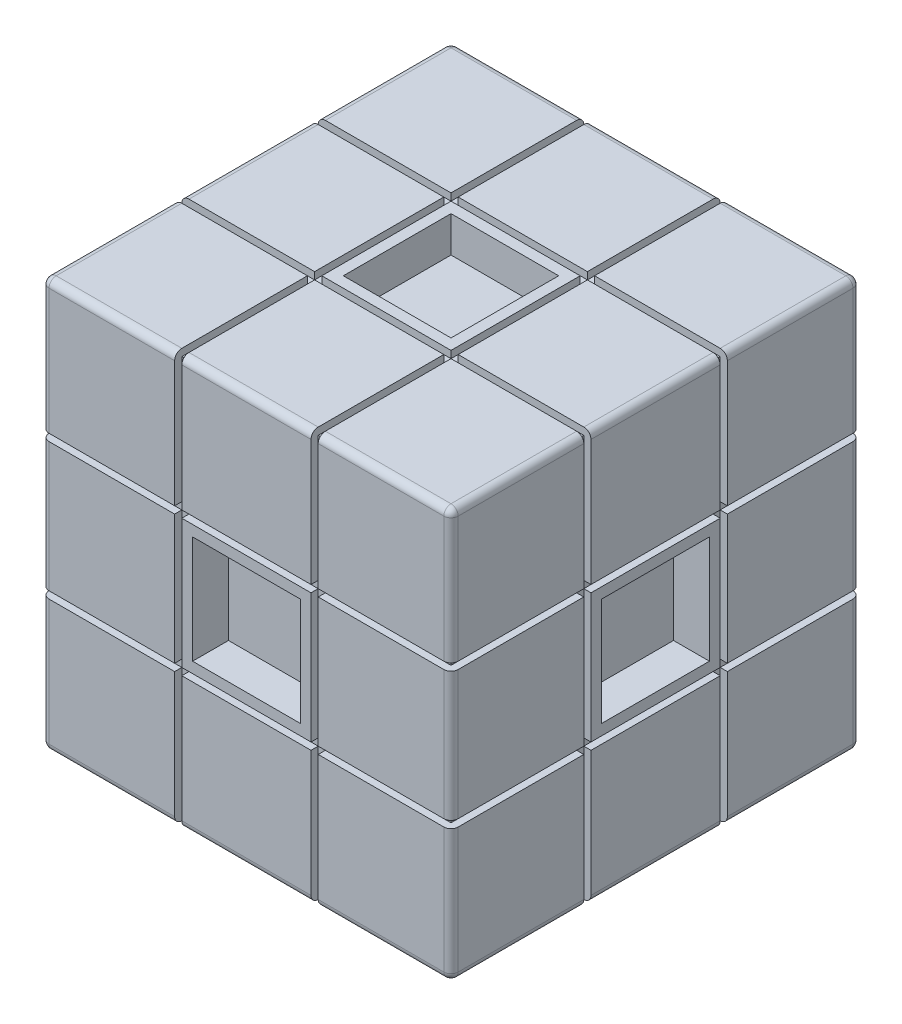
from build123d import *

# Parameters (mm, degrees)
SKETCH_1_W           = 57
SKETCH_1_H           = 57
EXTRUDE_1_DEPTH      = 57
SKETCH_2_W           = 15
SKETCH_2_H           = 15
CUT_EXTRUDE_3_DEPTH  = 5
SKETCH_5_W           = 15
SKETCH_5_H           = 15
CUT_EXTRUDE_4_DEPTH  = 5
SKETCH_6_W           = 15
SKETCH_6_H           = 15
CUT_EXTRUDE_5_DEPTH  = 5
SKETCH_8_W           = 15
SKETCH_8_H           = 15
CUT_EXTRUDE_6_DEPTH  = 5
SKETCH_9_W           = 15
SKETCH_9_H           = 15
CUT_EXTRUDE_7_DEPTH  = 5
SKETCH_10_W          = 15
SKETCH_10_H          = 15
CUT_EXTRUDE_8_DEPTH  = 5
SKETCH_12_W          = 18
SKETCH_12_H          = 18
CUT_EXTRUDE_9_DEPTH  = 1
SKETCH_13_W          = 1
SKETCH_13_H          = 1
CUT_EXTRUDE_10_DEPTH = 58
SKETCH_14_W          = 1
SKETCH_14_H          = 1
CUT_EXTRUDE_11_DEPTH = 58
SKETCH_15_W          = 1
SKETCH_15_H          = 1
CUT_EXTRUDE_12_DEPTH = 58
SKETCH_16_W          = 1
SKETCH_16_H          = 1
CUT_EXTRUDE_13_DEPTH = 58
FILLET_3_R           = 1
FILLET_4_R           = 1
FILLET_5_R           = 1


with BuildPart() as part:
    # 草图1 → 凸台-拉伸1 (new body)
    with BuildSketch(Plane(origin=(0, 0, 0), x_dir=(1, 0, 0), z_dir=(0, 1, 0))):
        with Locations((28.5, 28.5)):
            Rectangle(SKETCH_1_W, SKETCH_1_H)
    extrude(amount=EXTRUDE_1_DEPTH)

    # 草图2 → 切除-拉伸3 (cut)
    with BuildSketch(Plane(origin=(0, 0, 0), x_dir=(1, 0, 0), z_dir=(0, 1, 0))):
        with Locations((28.5, 28.5)):
            Rectangle(SKETCH_2_W, SKETCH_2_H)
    extrude(amount=CUT_EXTRUDE_3_DEPTH, mode=Mode.SUBTRACT)

    # 草图5 → 切除-拉伸4 (cut)
    with BuildSketch(Plane.XY):
        with Locations((28.5, 28.5)):
            Rectangle(SKETCH_5_W, SKETCH_5_H)
    extrude(amount=-CUT_EXTRUDE_4_DEPTH, mode=Mode.SUBTRACT)

    # 草图6 → 切除-拉伸5 (cut)
    with BuildSketch(Plane(origin=(0, 57, 0), x_dir=(1, 0, 0), z_dir=(0, 1, 0))):
        with Locations((28.5, 28.5)):
            Rectangle(SKETCH_6_W, SKETCH_6_H)
    extrude(amount=-CUT_EXTRUDE_5_DEPTH, mode=Mode.SUBTRACT)

    # 草图8 → 切除-拉伸6 (cut)
    with BuildSketch(Plane(origin=(0, 0, -57), x_dir=(-1, 0, 0), z_dir=(0, 0, -1))):
        with Locations((-28.5, 28.5)):
            Rectangle(SKETCH_8_W, SKETCH_8_H)
    extrude(amount=-CUT_EXTRUDE_6_DEPTH, mode=Mode.SUBTRACT)

    # 草图9 → 切除-拉伸7 (cut)
    with BuildSketch(Plane.ZY):
        with Locations((-28.5, 28.5)):
            Rectangle(SKETCH_9_W, SKETCH_9_H)
    extrude(amount=-CUT_EXTRUDE_7_DEPTH, mode=Mode.SUBTRACT)

    # 草图10 → 切除-拉伸8 (cut)
    with BuildSketch(Plane(origin=(57, 0, 0), x_dir=(0, 0, -1), z_dir=(1, 0, 0))):
        with Locations((28.5, 28.5)):
            Rectangle(SKETCH_10_W, SKETCH_10_H)
    extrude(amount=-CUT_EXTRUDE_8_DEPTH, mode=Mode.SUBTRACT)

    # 草图12 → 切除-拉伸9 (cut)
    with BuildSketch(Plane.XY):
        Polygon((38.5, 57), (38.5, 38.5), (57, 38.5), (57, 37.5), (38.5, 37.5), (38.5, 19.5), (57, 19.5), (57, 18.5), (38.5, 18.5), (38.5, 0), (37.5, 0), (37.5, 18.5), (19.5, 18.5), (19.5, 0), (18.5, 0), (18.5, 18.5), (0, 18.5), (0, 19.5), (18.5, 19.5), (18.5, 37.5), (0, 37.5), (0, 38.5), (18.5, 38.5), (18.5, 57), (19.5, 57), (19.5, 38.5), (37.5, 38.5), (37.5, 57), align=None)
        with Locations((28.5, 28.5)):
            Rectangle(SKETCH_12_W, SKETCH_12_H, mode=Mode.SUBTRACT)
    extrude(amount=-CUT_EXTRUDE_9_DEPTH, mode=Mode.SUBTRACT)

    # 草图13 → 切除-拉伸10 (cut, through all)
    with BuildSketch(Plane.XY):
        with Locations((19, 56.5)):
            Rectangle(SKETCH_13_W, SKETCH_13_H)
        with Locations((38, 56.5)):
            Rectangle(SKETCH_13_W, SKETCH_13_H)
        with Locations((38, 0.5)):
            Rectangle(SKETCH_13_W, SKETCH_13_H)
        with Locations((19, 0.5)):
            Rectangle(SKETCH_13_W, SKETCH_13_H)
        with Locations((0.5, 19)):
            Rectangle(SKETCH_13_W, SKETCH_13_H)
        with Locations((0.5, 38)):
            Rectangle(SKETCH_13_W, SKETCH_13_H)
        with Locations((56.5, 38)):
            Rectangle(SKETCH_13_W, SKETCH_13_H)
        with Locations((56.5, 19)):
            Rectangle(SKETCH_13_W, SKETCH_13_H)
    extrude(amount=-CUT_EXTRUDE_10_DEPTH, mode=Mode.SUBTRACT)

    # 草图14 → 切除-拉伸11 (cut, through all)
    with BuildSketch(Plane.ZY):
        with Locations((-56.5, 38)):
            Rectangle(SKETCH_14_W, SKETCH_14_H)
        with Locations((-56.5, 19)):
            Rectangle(SKETCH_14_W, SKETCH_14_H)
        with Locations((-19, 56.5)):
            Rectangle(SKETCH_14_W, SKETCH_14_H)
        with Locations((-38, 56.5)):
            Rectangle(SKETCH_14_W, SKETCH_14_H)
        with Locations((-38, 0.5)):
            Rectangle(SKETCH_14_W, SKETCH_14_H)
        with Locations((-19, 0.5)):
            Rectangle(SKETCH_14_W, SKETCH_14_H)
        with Locations((-0.5, 38)):
            Rectangle(SKETCH_14_W, SKETCH_14_H)
        with Locations((-0.5, 19)):
            Rectangle(SKETCH_14_W, SKETCH_14_H)
    extrude(amount=-CUT_EXTRUDE_11_DEPTH, mode=Mode.SUBTRACT)

    # 草图15 → 切除-拉伸12 (cut, through all)
    with BuildSketch(Plane(origin=(0, 57, 0), x_dir=(1, 0, 0), z_dir=(0, 1, 0))):
        with Locations((0.5, 19)):
            Rectangle(SKETCH_15_W, SKETCH_15_H)
        with Locations((0.5, 38)):
            Rectangle(SKETCH_15_W, SKETCH_15_H)
        with Locations((56.5, 38)):
            Rectangle(SKETCH_15_W, SKETCH_15_H)
        with Locations((56.5, 19)):
            Rectangle(SKETCH_15_W, SKETCH_15_H)
    extrude(amount=-CUT_EXTRUDE_12_DEPTH, mode=Mode.SUBTRACT)

    # 草图16 → 切除-拉伸13 (cut, through all)
    with BuildSketch(Plane.XZ):
        with Locations((19, -56.5)):
            Rectangle(SKETCH_16_W, SKETCH_16_H)
        with Locations((38, -56.5)):
            Rectangle(SKETCH_16_W, SKETCH_16_H)
    extrude(amount=-CUT_EXTRUDE_13_DEPTH, mode=Mode.SUBTRACT)

    # 圆角3
    fillet_3_edges = [part.edges().sort_by_distance(p)[0] for p in [
        (57, 28.5, 0),
        (57, 9.25, 0),
        (28.5, 0, 0),
        (47.75, 0, 0),
        (57, 0, -9.25),
        (57, 0, -47.75),
        (9.25, 0, 0),
        (57, 0, -28.5),
        (57, 47.75, 0),
    ]]
    fillet(fillet_3_edges, radius=FILLET_3_R)

    # 圆角4
    fillet_4_edges = [part.edges().sort_by_distance(p)[0] for p in [
        (47.25, 0, -57),
        (56.707106781, 0.292893219, -57),
        (0, 0.292893219, -0.292893219),
        (0, 28.5, 0),
        (0, 9.75, 0),
        (0, 9.25, -57),
        (28.5, 0, -57),
        (9.25, 0, -57),
        (0, 28.5, -57),
        (57, 28.5, -57),
        (57, 9.75, -57),
        (0, 0, -28.5),
        (0, 0, -9.75),
        (0, 0, -47.75),
        (0, 47.75, -57),
        (57, 47.75, -57),
        (0, 47.75, 0),
    ]]
    fillet(fillet_4_edges, radius=FILLET_4_R)

    # 圆角5
    fillet_5_edges = [part.edges().sort_by_distance(p)[0] for p in [
        (57, 57, -9.75),
        (56.707106781, 57, -0.292893219),
        (9.75, 57, 0),
        (0.292893219, 57, -0.292893219),
        (47.25, 57, -57),
        (56.707106781, 57, -56.707106781),
        (0, 57, -47.25),
        (0.292893219, 57, -56.707106781),
        (9.75, 57, -57),
        (28.5, 57, -57),
        (57, 57, -28.5),
        (0, 57, -9.75),
        (0, 57, -28.5),
        (57, 57, -47.25),
        (28.5, 57, 0),
        (47.25, 57, 0),
    ]]
    fillet(fillet_5_edges, radius=FILLET_5_R)


solid = part.part
